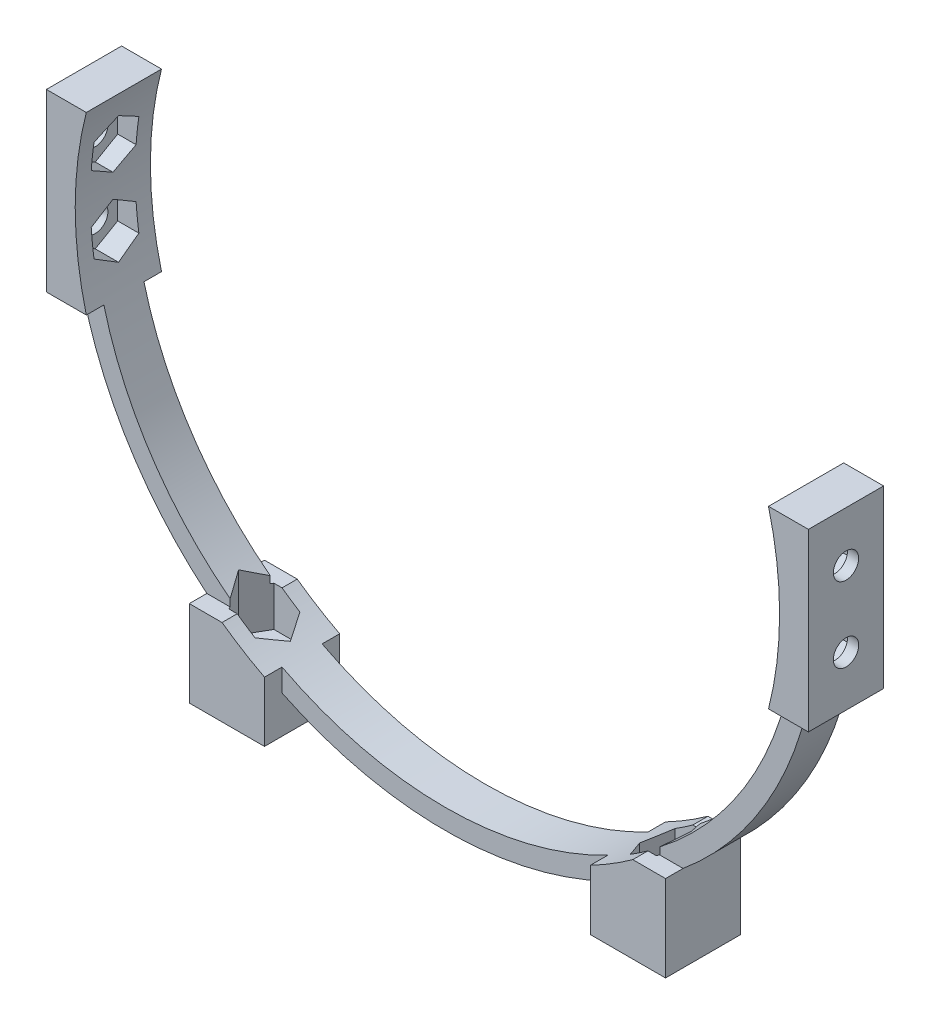
from build123d import *
from build123d.topology import SkipClean

# Parameters (mm, degrees)
BOSS_EXTRUDE1_DEPTH                 = 4
BOSS_EXTRUDE2_DEPTH                 = 7.5
CUT_EXTRUDE1_DEPTH                  = 3.5
F_8_0_199_DIAMETER_HOLE1_AT_2_COUNT = 2
F_8_0_199_DIAMETER_HOLE1_AT_2_PITCH = 15
BOSS_EXTRUDE3_REACH                 = 108.518
BOSS_EXTRUDE3_DIRECTION_2_REACH     = 108.518
CUT_EXTRUDE2_DEPTH                  = 3.5
CUT_EXTRUDE2_DEPTH_BACK             = 8
F_8_0_199_DIAMETER_HOLE2_D          = 5.0546
F_8_0_199_DIAMETER_HOLE2_DEPTH      = 11.481444958
F_8_0_199_DIAMETER_HOLE2_TIP        = 1.518555042


with BuildPart() as part:
    # Sketch1 → Boss-Extrude1 (new, symmetric)
    with BuildSketch(Plane.XY):
        with BuildLine():
            Line((-76, 17.5), (-76, -17.5))
            Line((-76, -17.5), (-72.163391169, -17.5))
            ThreePointArc((-72.163391169, -17.5), (0, -74.255), (72.163391169, -17.5))
            Line((72.163391169, -17.5), (76, -17.5))
            Line((76, -17.5), (76, 17.5))
            Line((76, 17.5), (68.04053957, 17.5))
            ThreePointArc((68.04053957, 17.5), (0, -70.255), (-68.04053957, 17.5))
            Line((-68.04053957, 17.5), (-76, 17.5))
        make_face()
    extrude(amount=BOSS_EXTRUDE1_DEPTH, both=True)

    # Sketch1_5 → Boss-Extrude2 (add, symmetric)
    with BuildSketch(Plane.XY):
        with BuildLine():
            Line((-76, 17.5), (-76, -17.5))
            Line((-76, -17.5), (-68.04053957, -17.5))
            ThreePointArc((-68.04053957, -17.5), (-70.255, 0), (-68.04053957, 17.5))
            Line((-68.04053957, 17.5), (-76, 17.5))
        make_face()
        with BuildLine():
            Line((68.04053957, -17.5), (76, -17.5))
            Line((76, -17.5), (76, 17.5))
            Line((76, 17.5), (68.04053957, 17.5))
            ThreePointArc((68.04053957, 17.5), (70.255, 0), (68.04053957, -17.5))
        make_face()
    extrude(amount=BOSS_EXTRUDE2_DEPTH, both=True)

    # Sketch2 → Cut-Extrude1 (cut, symmetric)
    with BuildSketch(Plane.ZY.offset(-70.255)):
        Polygon((0, 2.332715091), (4.475, 4.916357545), (4.475, 10.083642455), (0, 12.667284909), (-4.475, 10.083642455), (-4.475, 4.916357545), align=None)
        Polygon((0, -12.667284909), (4.475, -10.083642455), (4.475, -4.916357545), (0, -2.332715091), (-4.475, -4.916357545), (-4.475, -10.083642455), align=None)
    cut_extrude1 = extrude(amount=CUT_EXTRUDE1_DEPTH, both=True, mode=Mode.SUBTRACT)

    # Sketch4 → 8 _0.199_ Diameter Hole1 (revolve, cut)
    with BuildSketch(Plane(origin=(76, 7.5, 0), x_dir=(0, 0, -1), z_dir=(0, 1, 0))):
        Polygon((0, 0), (0, 10.71), (2.5273, 9.191444958), (2.5273, 0), align=None)
    f_8_0_199_diameter_hole1 = revolve(axis=Axis((82.35, 7.5, 0), (-1, 0, 0)), mode=Mode.SUBTRACT)

    # 8 _0.199_ Diameter Hole1 at 2: 8 _0.199_ Diameter Hole1 ×2
    with Locations(*[(0, -i * F_8_0_199_DIAMETER_HOLE1_AT_2_PITCH, 0) for i in range(1, F_8_0_199_DIAMETER_HOLE1_AT_2_COUNT)]):
        add(f_8_0_199_diameter_hole1, mode=Mode.SUBTRACT)

    # Mirror1: Cut-Extrude1, 8 _0.199_ Diameter Hole1 across plane
    add(cut_extrude1.mirror(Plane(origin=(0, 0, 0), x_dir=(0, 0, 1), z_dir=(1, 0, 0))), mode=Mode.SUBTRACT)
    add(f_8_0_199_diameter_hole1.mirror(Plane(origin=(0, 0, 0), x_dir=(0, 0, 1), z_dir=(1, 0, 0))), mode=Mode.SUBTRACT)

    # Mirror1 copy 1 sketch → Mirror1 copy 1 (revolve, cut)
    with BuildSketch(Plane(origin=(-76, -7.5, 0), x_dir=(0, 0, -1), z_dir=(0, 1, 0))):
        Polygon((0, 0), (0, -10.71), (2.5273, -9.191444958), (2.5273, 0), align=None)
    revolve(axis=Axis((-82.35, -7.5, 0), (-1, 0, 0)), mode=Mode.SUBTRACT)

    # Boss-Extrude3: up to this face of the body (flat: up to its plane)
    boss_extrude3_end = Plane(part.part.faces().sort_by_distance((-72.727295349, 0, 7.5))[0])
    # Sketch5 → Boss-Extrude3 (add, up to the picked face)
    with BuildSketch(Plane.XY, mode=Mode.PRIVATE) as boss_extrude3_sk1:
        with BuildLine():
            Line((47.5, -57.074994744), (47.5, -74.255))
            Line((47.5, -74.255), (32.5, -74.255))
            Line((32.5, -74.255), (32.5, -62.285752986))
            ThreePointArc((32.5, -62.285752986), (36.825261363, -59.830302946), (40.96596148, -57.074994744))
            Line((40.96596148, -57.074994744), (47.5, -57.074994744))
        make_face()
    boss_extrude3_tool1 = split(extrude(boss_extrude3_sk1.sketch, amount=BOSS_EXTRUDE3_REACH, mode=Mode.PRIVATE), bisect_by=boss_extrude3_end, keep=Keep.BOTH, mode=Mode.PRIVATE)
    # Sketch5 → Boss-Extrude3 (add, up to the picked face)
    with BuildSketch(Plane.XY, mode=Mode.PRIVATE) as boss_extrude3_sk2:
        with BuildLine():
            Line((-32.5, -74.255), (-47.5, -74.255))
            Line((-47.5, -74.255), (-47.5, -57.074994744))
            Line((-47.5, -57.074994744), (-40.96596148, -57.074994744))
            ThreePointArc((-40.96596148, -57.074994744), (-36.825261363, -59.830302946), (-32.5, -62.285752986))
            Line((-32.5, -62.285752986), (-32.5, -74.255))
        make_face()
    boss_extrude3_tool2 = split(extrude(boss_extrude3_sk2.sketch, amount=BOSS_EXTRUDE3_REACH, mode=Mode.PRIVATE), bisect_by=boss_extrude3_end, keep=Keep.BOTH, mode=Mode.PRIVATE)
    add(boss_extrude3_tool1.solids().sort_by(Axis((40.456136, -66.339152, 0), (0, 0, 1)))[0])
    add(boss_extrude3_tool2.solids().sort_by(Axis((-40.456136, -66.339152, 0), (0, 0, 1)))[0])

    # Boss-Extrude3 direction 2: up to this face of the body (flat: up to its plane)
    boss_extrude3_direction_2_end = Plane(part.part.faces().sort_by_distance((-72.727295349, 0, -7.5))[0])
    # Sketch5 → Boss-Extrude3 direction 2 (add, up to the picked face)
    with BuildSketch(Plane.XY, mode=Mode.PRIVATE) as boss_extrude3_direction_2_sk1:
        with BuildLine():
            Line((47.5, -57.074994744), (47.5, -74.255))
            Line((47.5, -74.255), (32.5, -74.255))
            Line((32.5, -74.255), (32.5, -62.285752986))
            ThreePointArc((32.5, -62.285752986), (36.825261363, -59.830302946), (40.96596148, -57.074994744))
            Line((40.96596148, -57.074994744), (47.5, -57.074994744))
        make_face()
    boss_extrude3_direction_2_tool1 = split(extrude(boss_extrude3_direction_2_sk1.sketch, amount=-BOSS_EXTRUDE3_DIRECTION_2_REACH, mode=Mode.PRIVATE), bisect_by=boss_extrude3_direction_2_end, keep=Keep.BOTH, mode=Mode.PRIVATE)
    # Sketch5 → Boss-Extrude3 direction 2 (add, up to the picked face)
    with BuildSketch(Plane.XY, mode=Mode.PRIVATE) as boss_extrude3_direction_2_sk2:
        with BuildLine():
            Line((-32.5, -74.255), (-47.5, -74.255))
            Line((-47.5, -74.255), (-47.5, -57.074994744))
            Line((-47.5, -57.074994744), (-40.96596148, -57.074994744))
            ThreePointArc((-40.96596148, -57.074994744), (-36.825261363, -59.830302946), (-32.5, -62.285752986))
            Line((-32.5, -62.285752986), (-32.5, -74.255))
        make_face()
    boss_extrude3_direction_2_tool2 = split(extrude(boss_extrude3_direction_2_sk2.sketch, amount=-BOSS_EXTRUDE3_DIRECTION_2_REACH, mode=Mode.PRIVATE), bisect_by=boss_extrude3_direction_2_end, keep=Keep.BOTH, mode=Mode.PRIVATE)
    add(boss_extrude3_direction_2_tool1.solids().sort_by(Axis((40.456136, -66.339152, 0), (0, 0, -1)))[0])
    add(boss_extrude3_direction_2_tool2.solids().sort_by(Axis((-40.456136, -66.339152, 0), (0, 0, -1)))[0])

    # Sketch6 → Cut-Extrude2 (cut, two sides: drawn at the far end of the back side and taken through both)
    with SkipClean():  # the faces are left unmerged after this step: merging them gives an invalid solid
        with BuildSketch(Plane(origin=(0, -57.074994744, 0), x_dir=(1, 0, 0), z_dir=(0, 1, 0)).offset(-CUT_EXTRUDE2_DEPTH_BACK)):
            Polygon((-37.416357545, -4.475), (-34.832715091, 0), (-37.416357545, 4.475), (-42.583642455, 4.475), (-45.167284909, 0), (-42.583642455, -4.475), align=None)
            Polygon((42.583642455, -4.475), (45.167284909, 0), (42.583642455, 4.475), (37.416357545, 4.475), (34.832715091, 0), (37.416357545, -4.475), align=None)
        extrude(amount=CUT_EXTRUDE2_DEPTH + CUT_EXTRUDE2_DEPTH_BACK, mode=Mode.SUBTRACT)

    # 8 _0.199_ Diameter Hole2
    with Locations(Plane(origin=(-40, -74.255, 0), x_dir=(0, 0, -1), z_dir=(0, -1, 0))):
        with Locations((0, 0), (0, 80)):
            Hole(F_8_0_199_DIAMETER_HOLE2_D / 2, depth=F_8_0_199_DIAMETER_HOLE2_DEPTH)
            with Locations((0, 0, -(F_8_0_199_DIAMETER_HOLE2_DEPTH + F_8_0_199_DIAMETER_HOLE2_TIP / 2))):  # 118° drill point
                Cone(0, F_8_0_199_DIAMETER_HOLE2_D / 2, F_8_0_199_DIAMETER_HOLE2_TIP, mode=Mode.SUBTRACT)


solid = part.part
